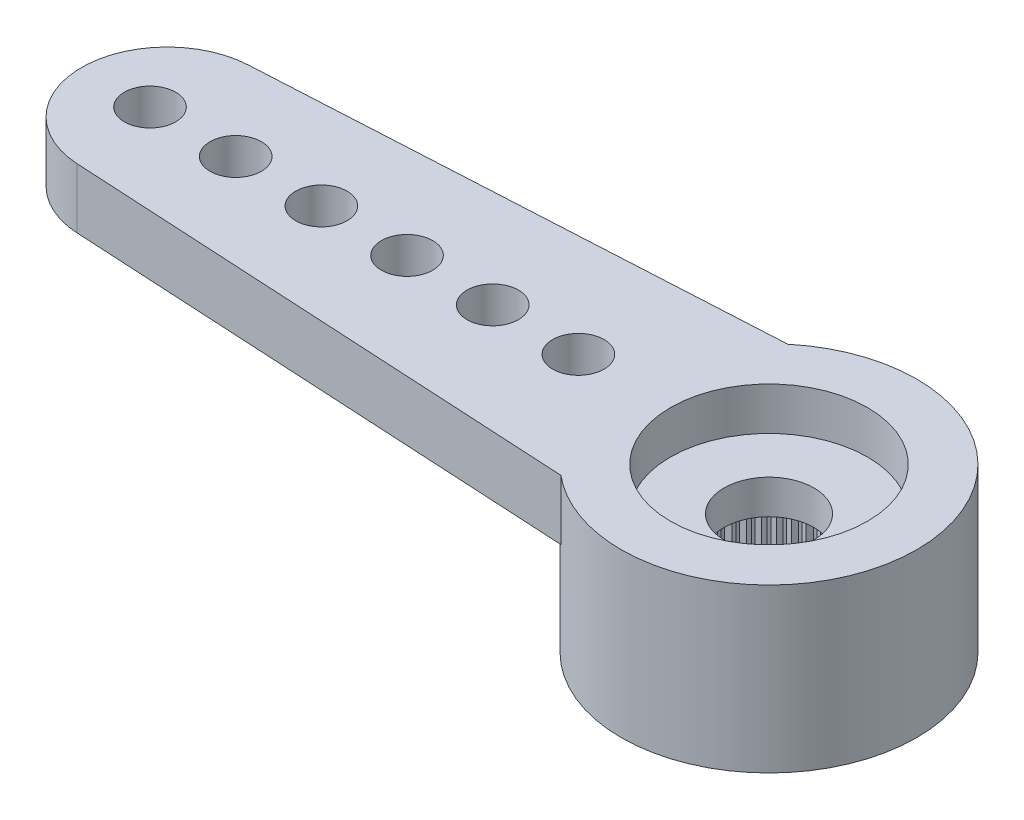
from build123d import *

# Parameters (mm, degrees)
RESSALTO_EXTRUS_O1_DEPTH = 1.4
ESBO_O2_R                = 3.45
RESSALTO_EXTRUS_O2_DEPTH = 2.4
FURO4_D                  = 1.2
PADR_O_LINEAR1_COUNT     = 6
PADR_O_LINEAR1_PITCH     = 2
FURO1_D                  = 4.95
FURO1_DEPTH              = 2
FURO2_D                  = 4.6
FURO2_DEPTH              = 1
FURO3_D                  = 2.1
RESSALTO_EXTRUS_O3_DEPTH = 2
PADR_OCIRCULAR1_COUNT    = 60


with BuildPart() as part:
    # Esboço1 → Ressalto-extrusão1 (new body)
    with BuildSketch(Plane(origin=(0, 0, 0), x_dir=(1, 0, 0), z_dir=(0, 1, 0))):
        with BuildLine():
            Line((-14.159121967, 1.99702088), (-2.209072203, 2.65))
            ThreePointArc((-2.209072203, 2.65), (3.45, 0), (-2.209072203, -2.65))
            Line((-2.209072203, -2.65), (-14.159121967, -1.99702088))
            ThreePointArc((-14.159121967, -1.99702088), (-16.05, 0), (-14.159121967, 1.99702088))
        make_face()
    extrude(amount=-RESSALTO_EXTRUS_O1_DEPTH)

    # Esboço2 → Ressalto-extrusão2 (add)
    with BuildSketch(Plane.XZ.offset(1.4)):
        Circle(ESBO_O2_R)
    extrude(amount=RESSALTO_EXTRUS_O2_DEPTH)

    # Furo4 (through all)
    with Locations(Plane(origin=(0, 0, 0), x_dir=(1, 0, 0), z_dir=(0, 1, 0))):
        with Locations((-14.45, 0)):
            furo4 = Hole(FURO4_D / 2)

    # Padrão linear1: Furo4 ×6
    with Locations(*[(i * PADR_O_LINEAR1_PITCH, 0, 0) for i in range(1, PADR_O_LINEAR1_COUNT)]):
        add(furo4, mode=Mode.SUBTRACT)

    # Furo1
    with Locations(Plane(origin=(0, -3.8, 0), x_dir=(-1, 0, 0), z_dir=(0, -1, 0))):
        with Locations((0, 0)):
            Hole(FURO1_D / 2, depth=FURO1_DEPTH)

    # Furo2
    with Locations(Plane(origin=(0, 0, 0), x_dir=(1, 0, 0), z_dir=(0, 1, 0))):
        with Locations((0, 0)):
            Hole(FURO2_D / 2, depth=FURO2_DEPTH)

    # Furo3 (through all)
    with Locations(Plane(origin=(0, 0, 0), x_dir=(1, 0, 0), z_dir=(0, 1, 0))):
        with Locations((0, 0)):
            Hole(FURO3_D / 2)

    # Esboço11 → Ressalto-extrusão3 (add)
    with BuildSketch(Plane.XZ.offset(3.8)):
        with BuildLine():
            Line((-0.098056786, 2.473056786), (0, 2.375))
            Line((0, 2.375), (0.098056786, 2.473056786))
            ThreePointArc((0.098056786, 2.473056786), (0, 2.475), (-0.098056786, 2.473056786))
        make_face()
    ressalto_extrus_o3 = extrude(amount=-RESSALTO_EXTRUS_O3_DEPTH)

    # PadrãoCircular1: Ressalto-extrusão3 ×60 about axis
    padr_ocircular1_axis = Axis((0, 0, 0), (0, 1, 0))
    for i in range(1, PADR_OCIRCULAR1_COUNT):
        add(ressalto_extrus_o3.rotate(padr_ocircular1_axis, i * 360 / PADR_OCIRCULAR1_COUNT))


solid = part.part
